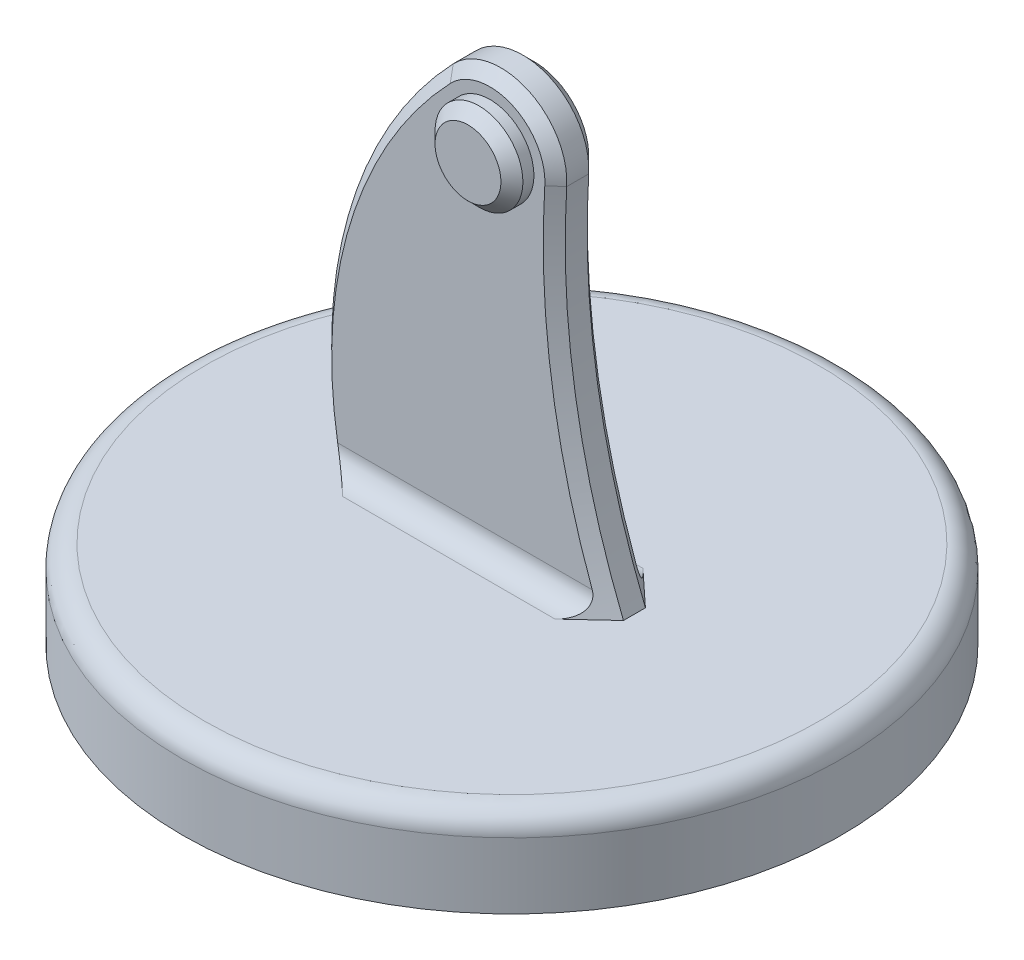
from build123d import *

# Parameters (mm, degrees)
SKETCH1_R           = 75
BOSS_EXTRUDE1_DEPTH = 20
FILLET1_R           = 5
BOSS_EXTRUDE2_DEPTH = 5
CHAMFER1_SIZE       = 2.5
FILLET2_R           = 5
SKETCH3_R           = 10
BOSS_EXTRUDE3_DEPTH = 5
CHAMFER2_SIZE       = 2.5
SKETCH4_R           = 5
CUT_EXTRUDE1_DEPTH  = 10


with BuildPart() as part:
    # Sketch1 → Boss-Extrude1 (new body)
    with BuildSketch(Plane(origin=(0, 0, 0), x_dir=(1, 0, 0), z_dir=(0, 1, 0))):
        Circle(SKETCH1_R)
    extrude(amount=BOSS_EXTRUDE1_DEPTH)

    # Fillet1
    fillet1_edges = [part.edges().sort_by_distance(p)[0] for p in [
        (-75, 20, 0),
    ]]
    fillet(fillet1_edges, radius=FILLET1_R)

    # Sketch2 → Boss-Extrude2 (add, symmetric)
    with BuildSketch(Plane.XY):
        with BuildLine():
            Line((-35, 15), (30, 15))
            ThreePointArc((30, 15), (17.428098582, 56.126843631), (14.970645506, 99.06203778))
            ThreePointArc((14.970645506, 99.06203778), (6.012327577, 113.742340307), (-10.849201429, 110.358321696))
            ThreePointArc((-10.849201429, 110.358321696), (-35.460543036, 65.854059614), (-35, 15))
        make_face()
    extrude(amount=BOSS_EXTRUDE2_DEPTH, both=True)

    # Chamfer1
    chamfer1_edges = [part.edges().sort_by_distance(p)[0] for p in [
        (-34.796467261, 68.341174934, -5),
        (16.970295051, 58.803839559, -5),
        (6.012327577, 113.742340307, -5),
        (16.970295051, 58.803839559, 5),
        (6.012327577, 113.742340307, 5),
        (-34.796467261, 68.341174934, 5),
    ]]
    chamfer(chamfer1_edges, length=CHAMFER1_SIZE)

    # Fillet2
    fillet2_edges = [part.edges().sort_by_distance(p)[0] for p in [
        (-4.241511046, 20, -5),
        (-4.241511046, 20, 5),
    ]]
    fillet(fillet2_edges, radius=FILLET2_R)

    # Sketch3 → Boss-Extrude3 (add)
    with BuildSketch(Plane.XY.offset(5)):
        with Locations((0, 100)):
            Circle(SKETCH3_R)
    extrude(amount=BOSS_EXTRUDE3_DEPTH)

    # Chamfer2
    chamfer2_edges = [part.edges().sort_by_distance(p)[0] for p in [
        (-10, 100, 10),
    ]]
    chamfer(chamfer2_edges, length=CHAMFER2_SIZE)

    # Sketch4 → Cut-Extrude1 (cut)
    with BuildSketch(Plane(origin=(0, 0, -5), x_dir=(-1, 0, 0), z_dir=(0, 0, -1))):
        with Locations((0, 100)):
            Circle(SKETCH4_R)
    extrude(amount=-CUT_EXTRUDE1_DEPTH, mode=Mode.SUBTRACT)


solid = part.part
